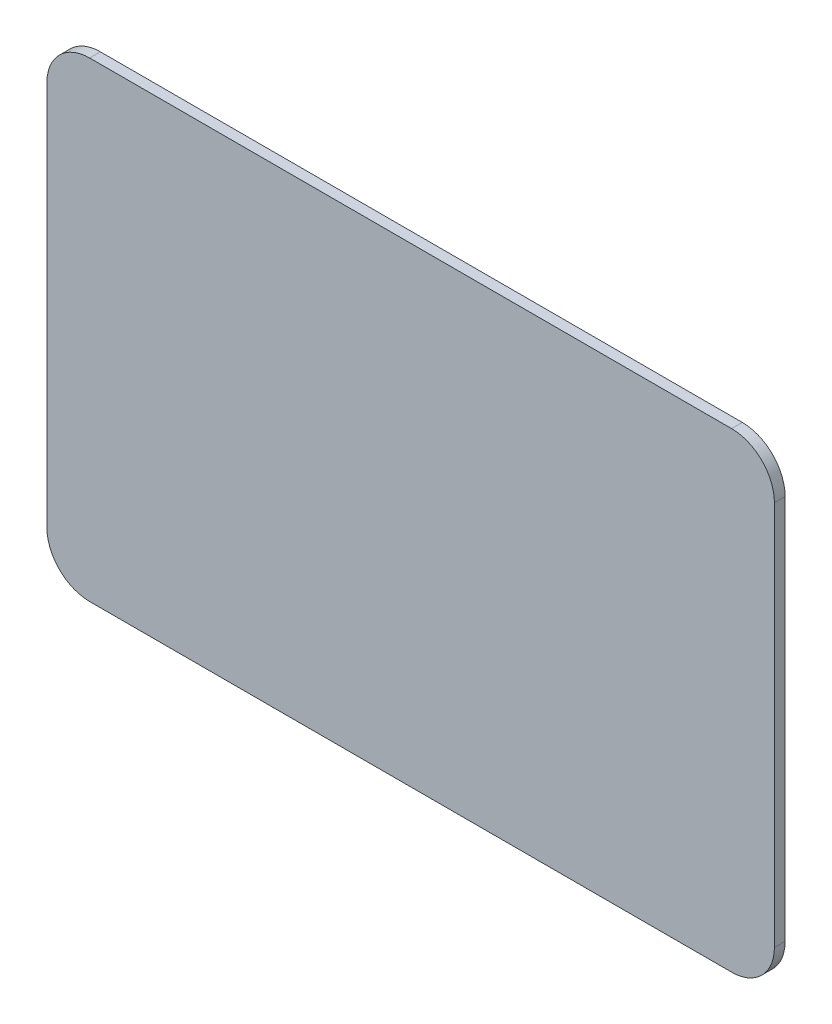
from build123d import *

# Parameters (mm, degrees)
SKETCH1_W           = 107.95
SKETCH1_H           = 69.85
BOSS_EXTRUDE1_DEPTH = 1.5875
FILLET1_R           = 6.35


with BuildPart() as part:
    # Sketch1 → Boss-Extrude1 (new body)
    with BuildSketch(Plane.XY):
        Rectangle(SKETCH1_W, SKETCH1_H)
    extrude(amount=BOSS_EXTRUDE1_DEPTH)

    # Fillet1
    fillet1_edges = [part.edges().sort_by_distance(p)[0] for p in [
        (53.975, -34.925, 0.79375),
        (-53.975, -34.925, 0.79375),
        (-53.975, 34.925, 0.79375),
        (53.975, 34.925, 0.79375),
    ]]
    fillet(fillet1_edges, radius=FILLET1_R)


solid = part.part
